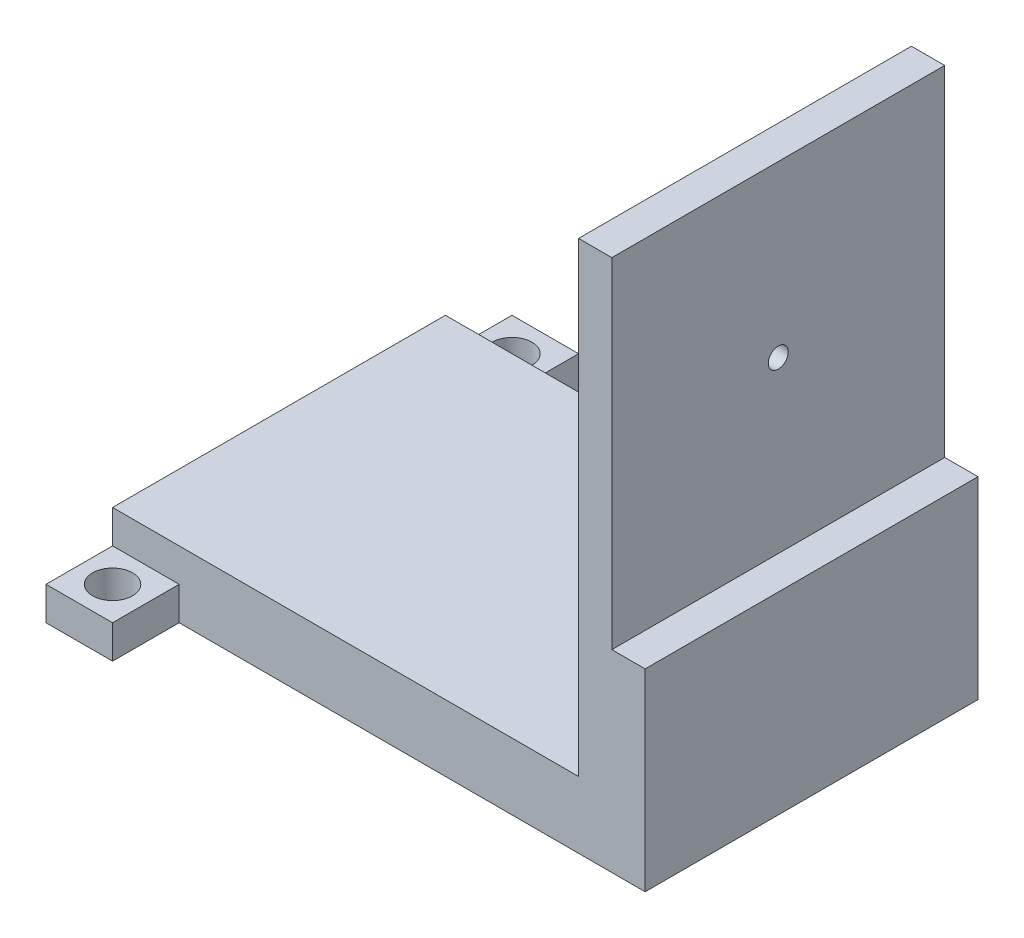
from build123d import *

# Parameters (mm, degrees)
SKETCH1_W           = 80
SKETCH1_H           = 50
BOSS_EXTRUDE1_DEPTH = 10
SKETCH2_W           = 10
SKETCH2_H           = 10
BOSS_EXTRUDE2_DEPTH = 10
SKETCH3_W           = 10
SKETCH3_H           = 10
CUT_EXTRUDE1_DEPTH  = 5
SKETCH4_R           = 3
CUT_EXTRUDE2_DEPTH  = 5
SKETCH5_W           = 10
SKETCH5_H           = 10
BOSS_EXTRUDE3_DEPTH = 10
SKETCH6_W           = 10
SKETCH6_H           = 10
CUT_EXTRUDE3_DEPTH  = 5
SKETCH7_R           = 3
CUT_EXTRUDE4_DEPTH  = 5
SKETCH10_W          = 10
SKETCH10_H          = 50
BOSS_EXTRUDE4_DEPTH = 70
SKETCH11_W          = 50
SKETCH11_H          = 51
CUT_EXTRUDE5_DEPTH  = 5
SKETCH12_R          = 1.5
CUT_EXTRUDE7_DEPTH  = 10


with BuildPart() as part:
    # Sketch1 → Boss-Extrude1 (new body)
    with BuildSketch(Plane(origin=(0, 0, 0), x_dir=(1, 0, 0), z_dir=(0, 1, 0))):
        with Locations((13.76, -10.152)):
            Rectangle(SKETCH1_W, SKETCH1_H)
    extrude(amount=BOSS_EXTRUDE1_DEPTH)

    # Sketch2 → Boss-Extrude2 (add)
    with BuildSketch(Plane.XY.offset(35.152)):
        with Locations((-21.24, 5)):
            Rectangle(SKETCH2_W, SKETCH2_H)
    extrude(amount=BOSS_EXTRUDE2_DEPTH)

    # Sketch3 → Cut-Extrude1 (cut)
    with BuildSketch(Plane(origin=(0, 10, 0), x_dir=(1, 0, 0), z_dir=(0, 1, 0))):
        with Locations((-21.24, -40.152)):
            Rectangle(SKETCH3_W, SKETCH3_H)
    extrude(amount=-CUT_EXTRUDE1_DEPTH, mode=Mode.SUBTRACT)

    # Sketch4 → Cut-Extrude2 (cut)
    with BuildSketch(Plane(origin=(0, 5, 0), x_dir=(1, 0, 0), z_dir=(0, 1, 0))):
        with Locations((-21.24, -40.152)):
            Circle(SKETCH4_R)
    extrude(amount=-CUT_EXTRUDE2_DEPTH, mode=Mode.SUBTRACT)

    # Sketch5 → Boss-Extrude3 (add)
    with BuildSketch(Plane(origin=(0, 0, -14.848), x_dir=(-1, 0, 0), z_dir=(0, 0, -1))):
        with Locations((21.24, 5)):
            Rectangle(SKETCH5_W, SKETCH5_H)
    extrude(amount=BOSS_EXTRUDE3_DEPTH)

    # Sketch6 → Cut-Extrude3 (cut)
    with BuildSketch(Plane(origin=(0, 10, 0), x_dir=(1, 0, 0), z_dir=(0, 1, 0))):
        with Locations((-21.24, 19.848)):
            Rectangle(SKETCH6_W, SKETCH6_H)
    extrude(amount=-CUT_EXTRUDE3_DEPTH, mode=Mode.SUBTRACT)

    # Sketch7 → Cut-Extrude4 (cut)
    with BuildSketch(Plane(origin=(0, 5, 0), x_dir=(1, 0, 0), z_dir=(0, 1, 0))):
        with Locations((-21.24, 19.848)):
            Circle(SKETCH7_R)
    extrude(amount=-CUT_EXTRUDE4_DEPTH, mode=Mode.SUBTRACT)

    # Sketch10 → Boss-Extrude4 (add)
    with BuildSketch(Plane(origin=(0, 10, 0), x_dir=(1, 0, 0), z_dir=(0, 1, 0))):
        with Locations((48.76, -10.152)):
            Rectangle(SKETCH10_W, SKETCH10_H)
    extrude(amount=BOSS_EXTRUDE4_DEPTH)

    # Sketch11 → Cut-Extrude5 (cut)
    with BuildSketch(Plane(origin=(53.76, 0, 0), x_dir=(0, 0, -1), z_dir=(1, 0, 0))):
        with Locations((-10.152, 54.5)):
            Rectangle(SKETCH11_W, SKETCH11_H)
    extrude(amount=-CUT_EXTRUDE5_DEPTH, mode=Mode.SUBTRACT)

    # Sketch12 → Cut-Extrude7 (cut)
    with BuildSketch(Plane(origin=(48.76, 0, 0), x_dir=(0, 0, -1), z_dir=(1, 0, 0))):
        with Locations((-10.152, 54.5)):
            Circle(SKETCH12_R)
    extrude(amount=-CUT_EXTRUDE7_DEPTH, mode=Mode.SUBTRACT)


solid = part.part
